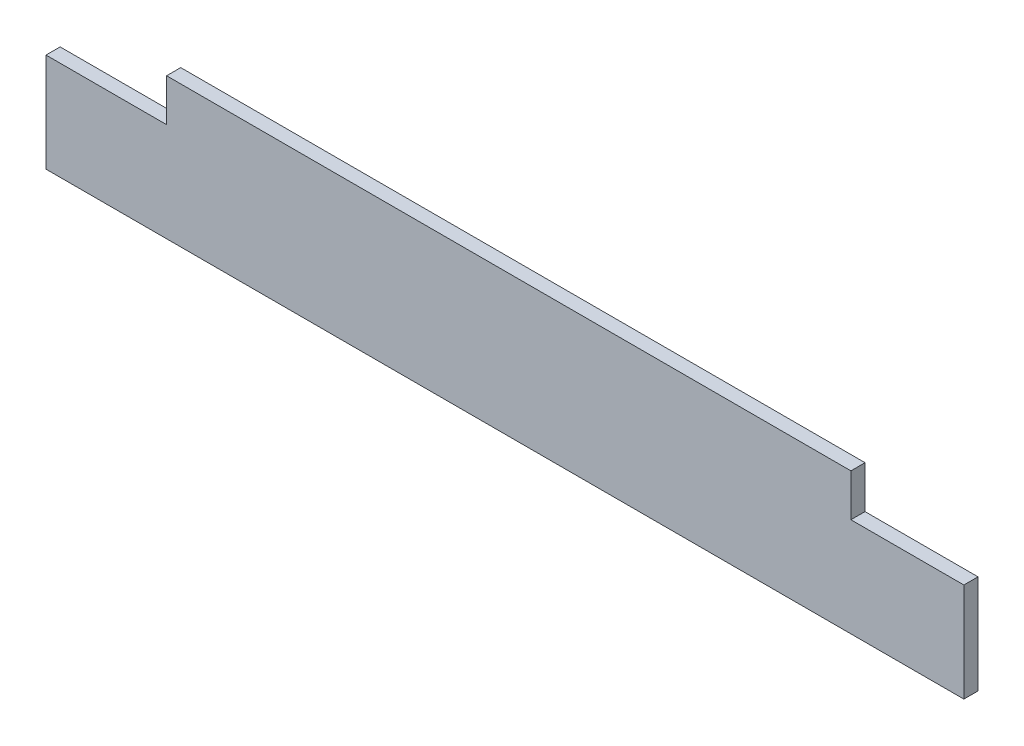
from build123d import *

# Parameters (mm, degrees)
BOSS_EXTRU_1_DEPTH = 10


with BuildPart() as part:
    # Esquisse1 → Boss.-Extru.1 (new body)
    with BuildSketch(Plane.XY):
        Polygon((-325, -149.452554745), (-325, -219.452554745), (325, -219.452554745), (325, -149.452554745), (245, -149.452554745), (245, -119.452554745), (-239.598540146, -119.452554745), (-239.598540146, -149.452554745), align=None)
    extrude(amount=BOSS_EXTRU_1_DEPTH)


solid = part.part
